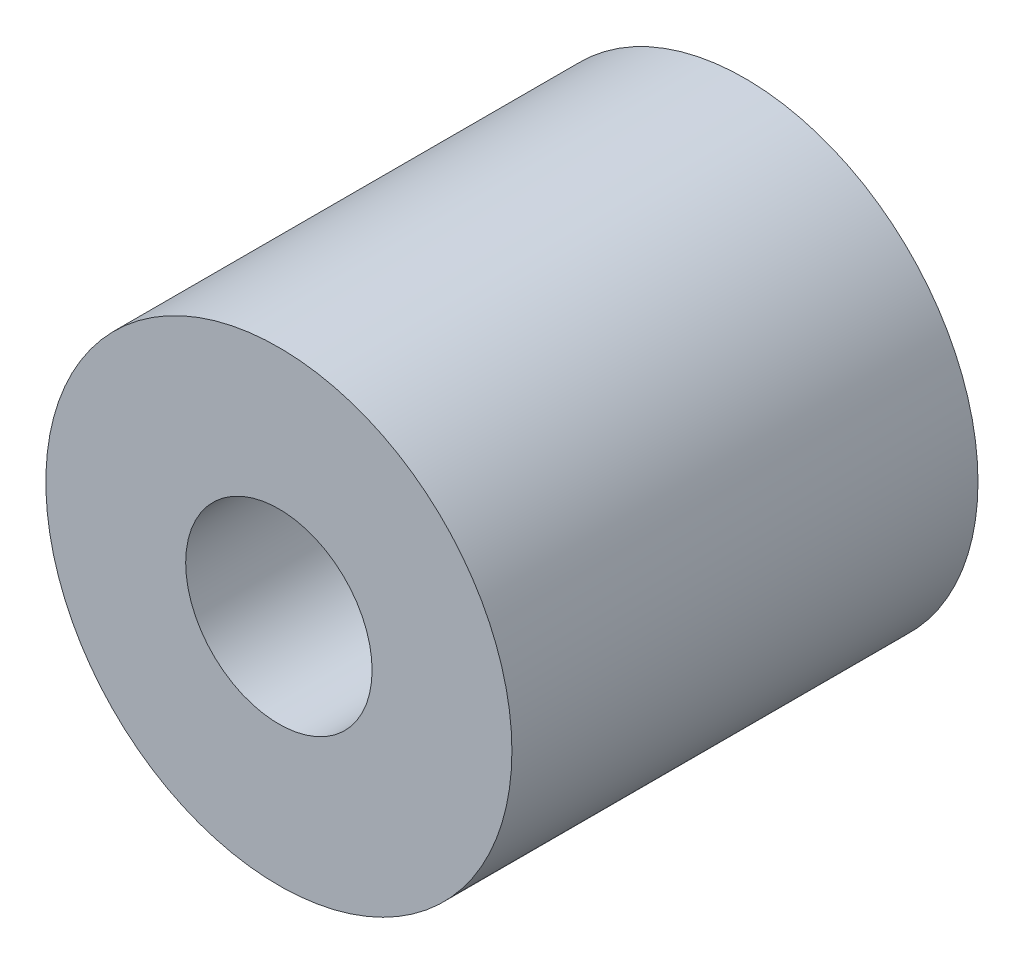
from build123d import *

# Parameters (mm, degrees)
ESBO_O1_R                = 5
ESBO_O1_R_2              = 2
RESSALTO_EXTRUS_O1_DEPTH = 10


with BuildPart() as part:
    # Esboço1 → Ressalto-extrusão1 (new body)
    with BuildSketch(Plane.XY):
        Circle(ESBO_O1_R)
        Circle(ESBO_O1_R_2, mode=Mode.SUBTRACT)
    extrude(amount=RESSALTO_EXTRUS_O1_DEPTH)


solid = part.part
